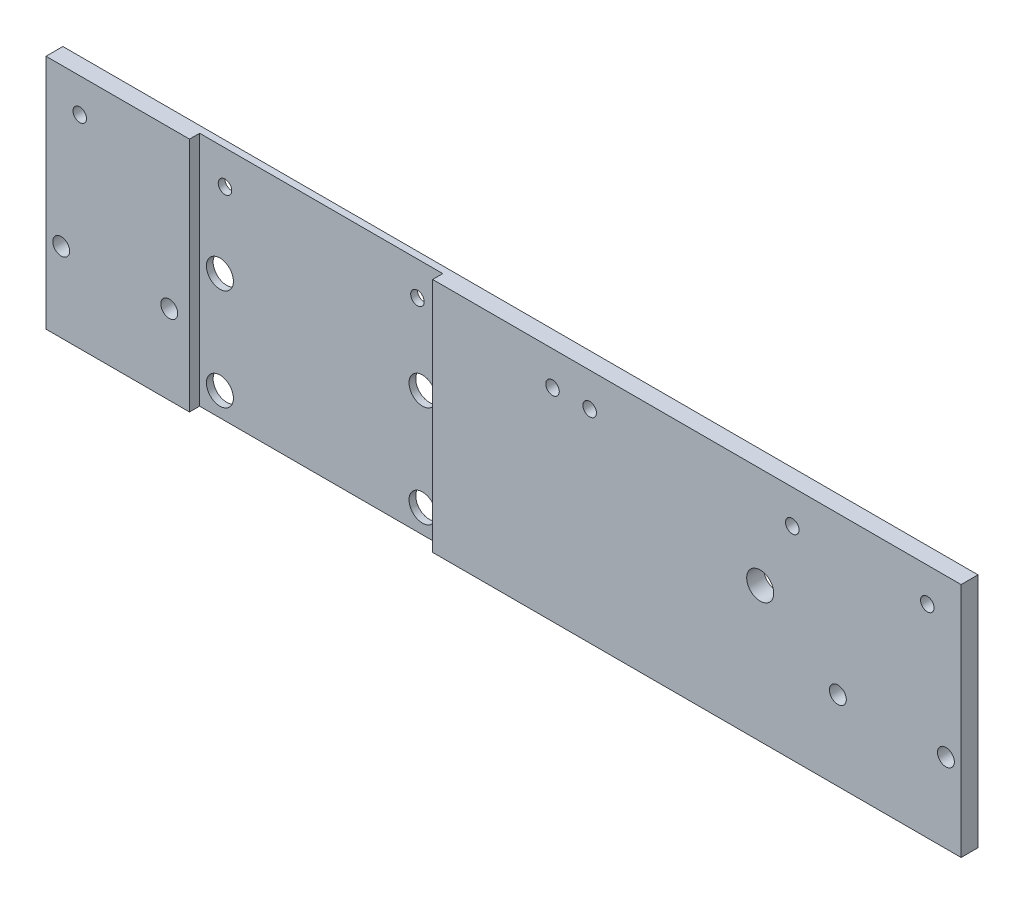
from build123d import *

# Parameters (mm, degrees)
SKIZZE1_W                       = 271
SKIZZE1_H                       = 70
AUFSATZ_LINEAR_AUSTRAGEN1_DEPTH = 5
SKIZZE2_W                       = 72
SKIZZE2_H                       = 70
SCHNITT_LINEAR_AUSTRAGEN1_DEPTH = 3
SKIZZE3_R                       = 4
SCHNITT_LINEAR_AUSTRAGEN2_DEPTH = 10
SKIZZE4_R                       = 2.5
SCHNITT_LINEAR_AUSTRAGEN3_DEPTH = 10
SKIZZE5_R                       = 2.5
SCHNITT_LINEAR_AUSTRAGEN4_DEPTH = 10
SKIZZE6_R                       = 2
SCHNITT_LINEAR_AUSTRAGEN5_DEPTH = 10
SKIZZE7_R                       = 4
SCHNITT_LINEAR_AUSTRAGEN6_DEPTH = 10
SKIZZE8_R                       = 2
SCHNITT_LINEAR_AUSTRAGEN7_DEPTH = 10


with BuildPart() as part:
    # Skizze1 → Aufsatz-Linear austragen1 (new body)
    with BuildSketch(Plane.XY):
        with Locations((135.5, 35)):
            Rectangle(SKIZZE1_W, SKIZZE1_H)
    extrude(amount=AUFSATZ_LINEAR_AUSTRAGEN1_DEPTH)

    # Skizze2 → Schnitt-Linear austragen1 (cut)
    with BuildSketch(Plane.XY.offset(5)):
        with Locations((78.5, 35)):
            Rectangle(SKIZZE2_W, SKIZZE2_H)
    extrude(amount=-SCHNITT_LINEAR_AUSTRAGEN1_DEPTH, mode=Mode.SUBTRACT)

    # Skizze3 → Schnitt-Linear austragen2 (cut)
    with BuildSketch(Plane(origin=(0, 0, 0), x_dir=(-1, 0, 0), z_dir=(0, 0, -1))):
        with Locations((-48.5, 37)):
            Circle(SKIZZE3_R)
        with Locations((-108.5, 37)):
            Circle(SKIZZE3_R)
        with Locations((-108.5, 7)):
            Circle(SKIZZE3_R)
        with Locations((-48.5, 7)):
            Circle(SKIZZE3_R)
    extrude(amount=-SCHNITT_LINEAR_AUSTRAGEN2_DEPTH, mode=Mode.SUBTRACT)

    # Skizze4 → Schnitt-Linear austragen3 (cut)
    with BuildSketch(Plane(origin=(0, 0, 0), x_dir=(-1, 0, 0), z_dir=(0, 0, -1))):
        with Locations((-234.5, 23.5)):
            Circle(SKIZZE4_R)
        with Locations((-266.5, 23.5)):
            Circle(SKIZZE4_R)
    extrude(amount=-SCHNITT_LINEAR_AUSTRAGEN3_DEPTH, mode=Mode.SUBTRACT)

    # Skizze5 → Schnitt-Linear austragen4 (cut)
    with BuildSketch(Plane(origin=(0, 0, 0), x_dir=(-1, 0, 0), z_dir=(0, 0, -1))):
        with Locations((-36.5, 23.5)):
            Circle(SKIZZE5_R)
        with Locations((-4.5, 23.5)):
            Circle(SKIZZE5_R)
    extrude(amount=-SCHNITT_LINEAR_AUSTRAGEN4_DEPTH, mode=Mode.SUBTRACT)

    # Skizze6 → Schnitt-Linear austragen5 (cut)
    with BuildSketch(Plane(origin=(0, 0, 0), x_dir=(-1, 0, 0), z_dir=(0, 0, -1))):
        with Locations((-10, 60)):
            Circle(SKIZZE6_R)
        with Locations((-50, 60)):
            Circle(SKIZZE6_R)
        with Locations((-161, 60)):
            Circle(SKIZZE6_R)
        with Locations((-221, 60)):
            Circle(SKIZZE6_R)
        with Locations((-261, 60)):
            Circle(SKIZZE6_R)
        with Locations((-107, 60)):
            Circle(SKIZZE6_R)
    extrude(amount=-SCHNITT_LINEAR_AUSTRAGEN5_DEPTH, mode=Mode.SUBTRACT)

    # Skizze7 → Schnitt-Linear austragen6 (cut)
    with BuildSketch(Plane(origin=(0, 0, 0), x_dir=(-1, 0, 0), z_dir=(0, 0, -1))):
        with Locations((-211.5, 40)):
            Circle(SKIZZE7_R)
    extrude(amount=-SCHNITT_LINEAR_AUSTRAGEN6_DEPTH, mode=Mode.SUBTRACT)

    # Skizze8 → Schnitt-Linear austragen7 (cut)
    with BuildSketch(Plane(origin=(0, 0, 0), x_dir=(-1, 0, 0), z_dir=(0, 0, -1))):
        with Locations((-150, 60)):
            Circle(SKIZZE8_R)
    extrude(amount=-SCHNITT_LINEAR_AUSTRAGEN7_DEPTH, mode=Mode.SUBTRACT)


solid = part.part
